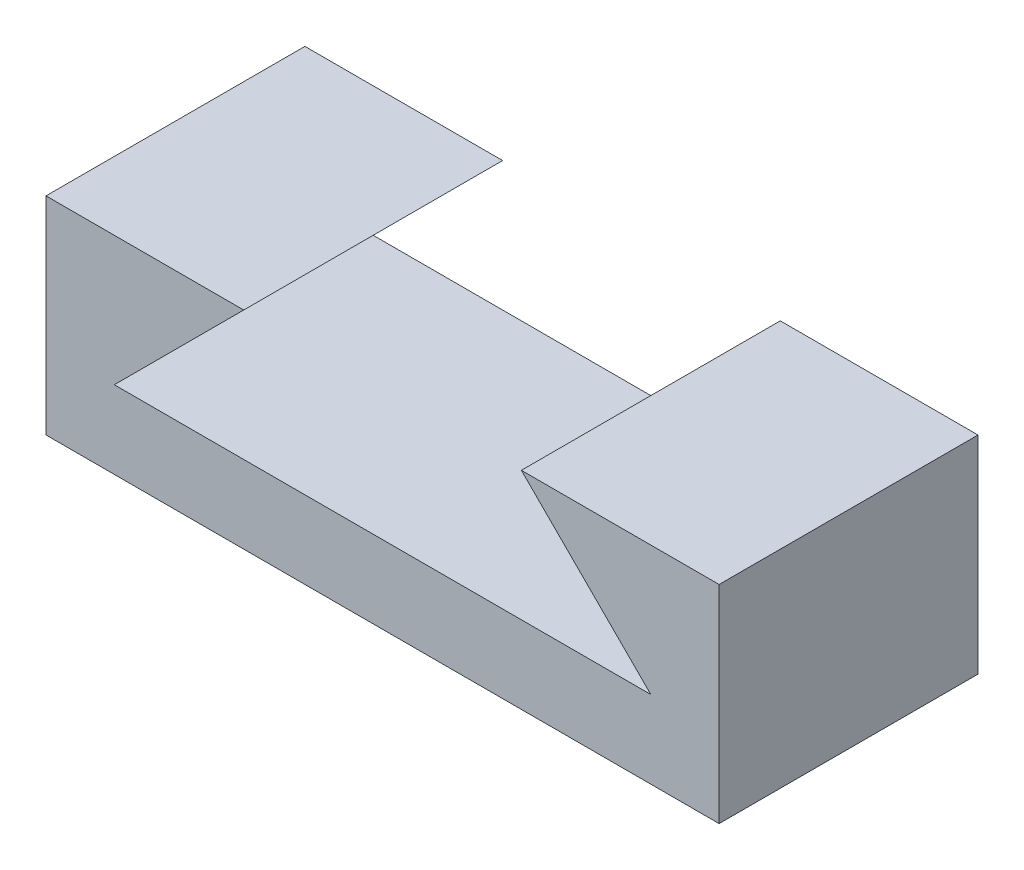
from build123d import *

# Parameters (mm, degrees)
SALIENTE_EXTRUIR1_DEPTH = 10


with BuildPart() as part:
    # Croquis1 → Saliente-Extruir1 (new body)
    with BuildSketch(Plane.XY):
        Polygon((-10.297261842, 0.464840426), (-5.659393877, 0.464840426), (-10.659393877, -4.535159574), (10.064870192, -4.535159574), (5.064870192, 0.464840426), (9.702738158, 0.464840426), (12.702738158, 0.464840426), (12.702738158, -7.535159574), (-13.297261842, -7.535159574), (-13.297261842, 0.464840426), align=None)
    extrude(amount=SALIENTE_EXTRUIR1_DEPTH)


solid = part.part
